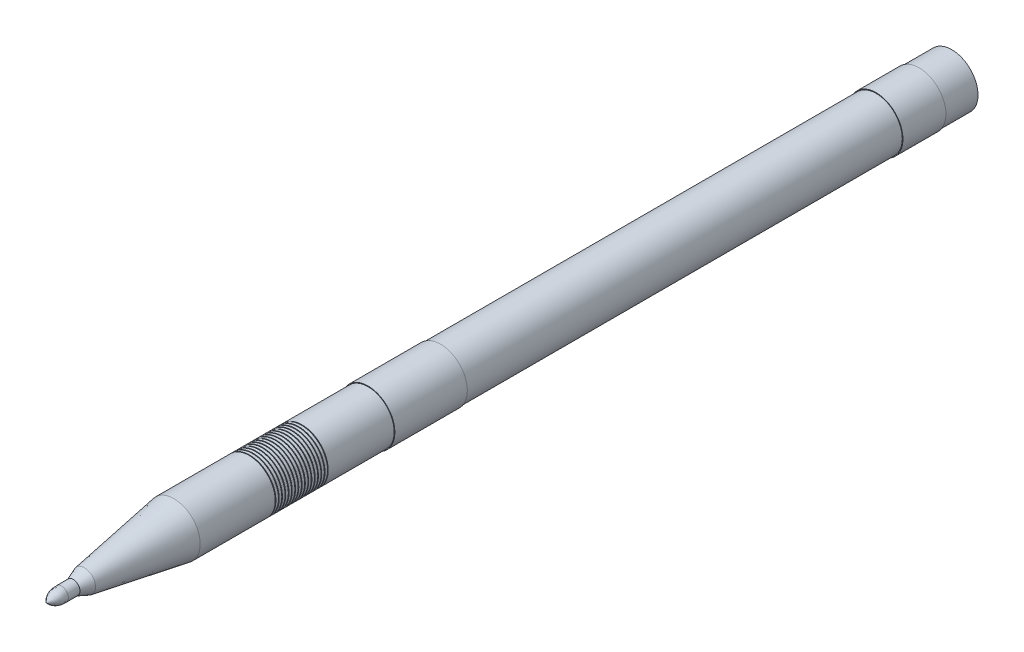
from build123d import *

# Parameters (mm, degrees)
SKETCH2_R          = 0.25
CUT_EXTRUDE1_DEPTH = 2


with BuildPart() as part:
    # Sketch1 → Revolve1 (revolve)
    with BuildSketch(Plane(origin=(0, 0, 0), x_dir=(0, 0, -1), z_dir=(1, 0, 0))):
        with BuildLine():
            Line((0, 0), (1384, 0))
            Line((1384, 0), (1384, 40))
            Line((1384, 40), (1334, 40))
            Line((1334, 40), (1334, 41))
            Line((1334, 41), (1268.293836549, 41))
            Line((1268.293836549, 41), (1268.293836549, 40))
            Line((1268.293836549, 40), (602.5527216, 40))
            Line((602.5527216, 40), (602.5527216, 41))
            Line((602.5527216, 41), (491.814643733, 41))
            Line((491.814643733, 41), (491.814643733, 40))
            Line((491.814643733, 40), (391, 40))
            Line((391, 40), (391, 38))
            Line((391, 38), (390, 38))
            Line((390, 38), (390, 40))
            Line((390, 40), (386, 40))
            Line((386, 40), (386, 38))
            Line((386, 38), (385, 38))
            Line((385, 38), (385, 40))
            Line((385, 40), (381, 40))
            Line((381, 40), (381, 38))
            Line((381, 38), (380, 38))
            Line((380, 38), (380, 40))
            Line((380, 40), (376, 40))
            Line((376, 40), (376, 38))
            Line((376, 38), (375, 38))
            Line((375, 38), (375, 40))
            Line((375, 40), (371, 40))
            Line((371, 40), (371, 38))
            Line((371, 38), (370, 38))
            Line((370, 38), (370, 40))
            Line((370, 40), (366, 40))
            Line((366, 40), (366, 38))
            Line((366, 38), (365, 38))
            Line((365, 38), (365, 40))
            Line((365, 40), (361, 40))
            Line((361, 40), (361, 38))
            Line((361, 38), (360, 38))
            Line((360, 38), (360, 40))
            Line((360, 40), (356, 40))
            Line((356, 40), (356, 38))
            Line((356, 38), (355, 38))
            Line((355, 38), (355, 40))
            Line((355, 40), (351, 40))
            Line((351, 40), (351, 38))
            Line((351, 38), (350, 38))
            Line((350, 38), (350, 40))
            Line((350, 40), (346, 40))
            Line((346, 40), (346, 38))
            Line((346, 38), (345, 38))
            Line((345, 38), (345, 40))
            Line((345, 40), (341, 40))
            Line((341, 40), (341, 38))
            Line((341, 38), (340, 38))
            Line((340, 38), (340, 40))
            Line((340, 40), (336, 40))
            Line((336, 40), (336, 38))
            Line((336, 38), (335, 38))
            Line((335, 38), (335, 40))
            Line((335, 40), (331, 40))
            Line((331, 40), (331, 38))
            Line((331, 38), (330, 38))
            Line((330, 38), (330, 40))
            Line((330, 40), (326, 40))
            Line((326, 40), (326, 38))
            Line((326, 38), (325, 38))
            Line((325, 38), (325, 40))
            Line((325, 40), (321, 40))
            Line((321, 40), (321, 38))
            Line((321, 38), (320, 38))
            Line((320, 38), (320, 40))
            Line((320, 40), (316, 40))
            Line((316, 40), (316, 38))
            Line((316, 38), (315, 38))
            Line((315, 38), (315, 40))
            Line((315, 40), (311, 40))
            Line((311, 40), (311, 38))
            Line((311, 38), (310, 38))
            Line((310, 38), (310, 40))
            Line((310, 40), (195.273854845, 40))
            Line((195.273854845, 40), (58.322381463, 17.134585546))
            Line((58.322381463, 17.134585546), (41.118688653, 10.459369626))
            Line((41.118688653, 10.459369626), (23.382481666, 10.459369626))
            add(Edge.make_bspline(
                [(0, 0), (8.502952107, 11.311882761), (23.382481666, 10.459369626)],
                knots=[0, 0, 0, 1, 1, 1], degree=2))
        make_face()
    revolve(axis=Axis((0, 0, 0), (0, 0, -1)))

    # Sketch2 → Cut-Extrude1 (cut)
    with BuildSketch(Plane(origin=(0, 40, 0), x_dir=(1, 0, 0), z_dir=(0, 1, 0))):
        with Locations((0, 1359)):
            Circle(SKETCH2_R)
    extrude(amount=-CUT_EXTRUDE1_DEPTH, mode=Mode.SUBTRACT)


solid = part.part
